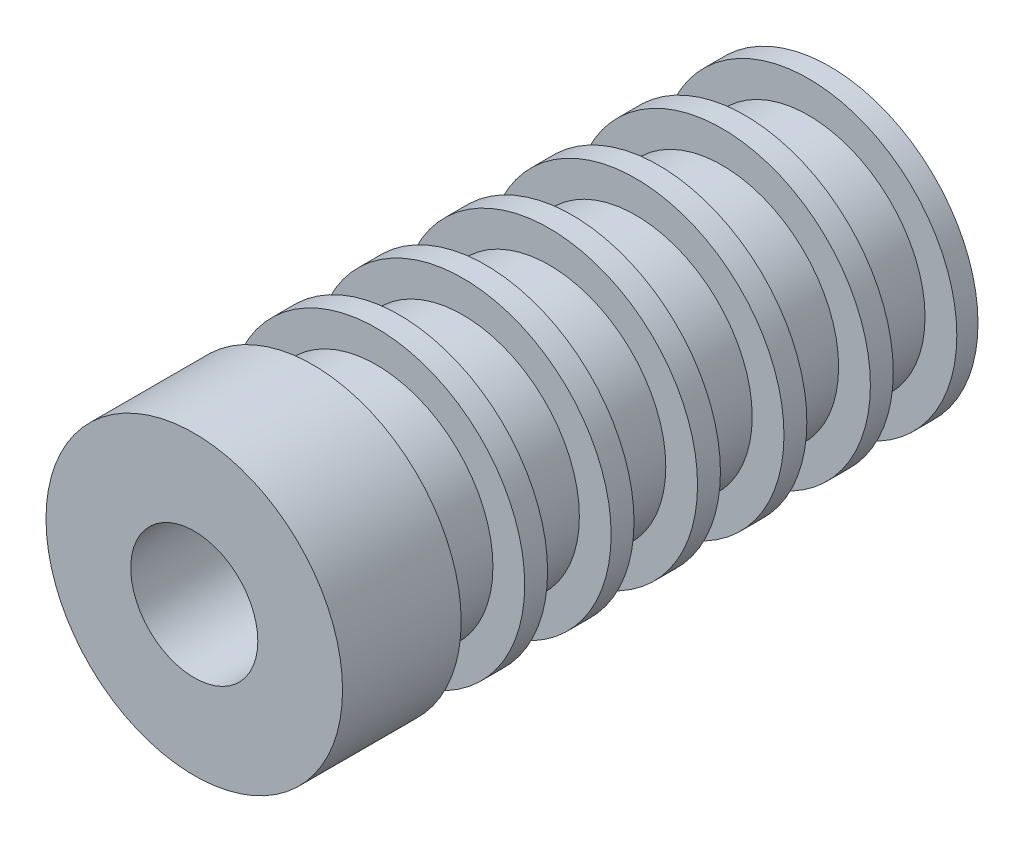
from build123d import *

# Parameters (mm, degrees)
SKETCH1_R          = 11.1125
SKETCH1_R_2        = 3.2004
EXTRUDE1_DEPTH     = 25.4
SKETCH5_R          = 11.1125
SKETCH5_R_2        = 3.2004
CUT_EXTRUDE1_DEPTH = 3.175
SKETCH6_R          = 4.7625
CUT_EXTRUDE2_DEPTH = 48.625
CUT_EXTRUDE3_START = -1.5875
SKETCH7_R          = 11.1125
SKETCH7_R_2        = 8.73125
CUT_EXTRUDE3_DEPTH = 4.7625
LPATTERN1_COUNT    = 6
LPATTERN1_PITCH    = 6.477


with BuildPart() as part:
    # Sketch1 → Extrude1 (new body, symmetric)
    with BuildSketch(Plane.XY):
        Circle(SKETCH1_R)
        Circle(SKETCH1_R_2, mode=Mode.SUBTRACT)
    extrude(amount=EXTRUDE1_DEPTH, both=True)

    # Sketch5 → Cut-Extrude1 (cut)
    with BuildSketch(Plane.XY.offset(25.4)):
        Circle(SKETCH5_R)
        Circle(SKETCH5_R_2, mode=Mode.SUBTRACT)
    extrude(amount=-CUT_EXTRUDE1_DEPTH, mode=Mode.SUBTRACT)

    # Sketch6 → Cut-Extrude2 (cut, through all)
    with BuildSketch(Plane.XY.offset(22.225)):
        Circle(SKETCH6_R)
    extrude(amount=-CUT_EXTRUDE2_DEPTH, mode=Mode.SUBTRACT)

    # Sketch7 → Cut-Extrude3 (cut)
    with BuildSketch(Plane(origin=(0, 0, -25.4), x_dir=(-1, 0, 0), z_dir=(0, 0, -1)).offset(CUT_EXTRUDE3_START)):
        Circle(SKETCH7_R)
        Circle(SKETCH7_R_2, mode=Mode.SUBTRACT)
    cut_extrude3 = extrude(amount=-CUT_EXTRUDE3_DEPTH, mode=Mode.SUBTRACT)

    # LPattern1: Cut-Extrude3 ×6
    with Locations(*[(0, 0, i * LPATTERN1_PITCH) for i in range(1, LPATTERN1_COUNT)]):
        add(cut_extrude3, mode=Mode.SUBTRACT)


solid = part.part
